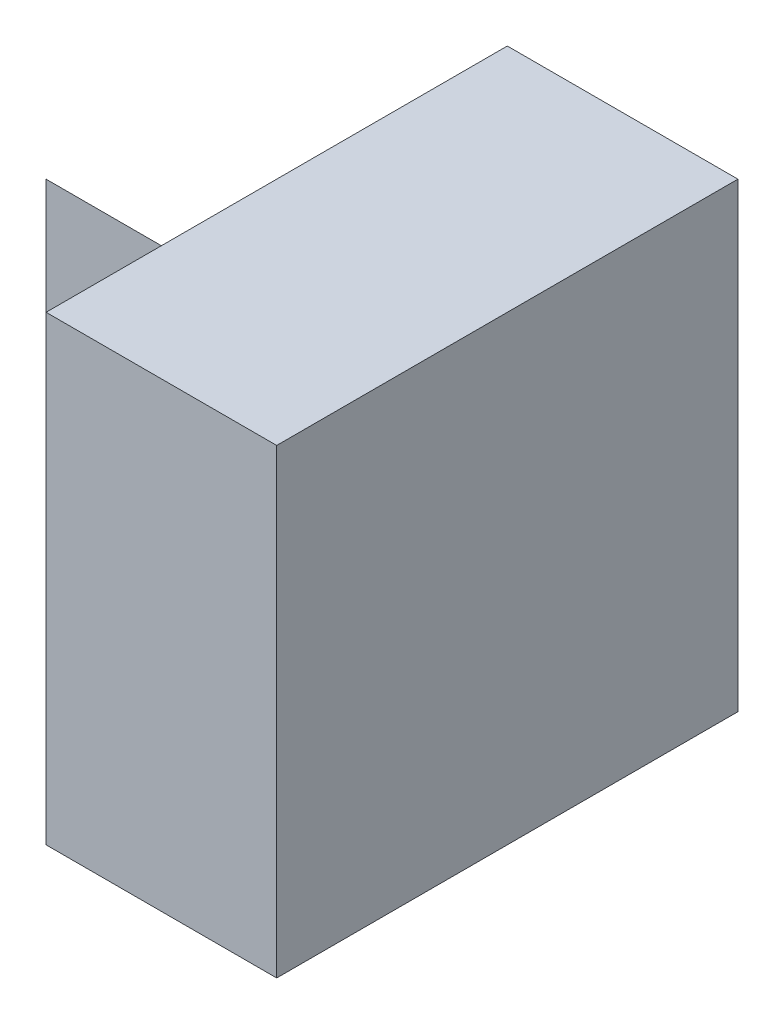
from build123d import *

# Parameters (mm, degrees)
SKETCH1_W           = 4
SKETCH1_H           = 4
BOSS_EXTRUDE1_DEPTH = 2
SKETCH2_W           = 2
SKETCH2_H           = 3
BOSS_EXTRUDE2_DEPTH = 2
CUT_EXTRUDE1_DEPTH  = 2


with BuildPart() as part:
    # Sketch1 → Boss-Extrude1 (new body)
    with BuildSketch(Plane(origin=(0, 0, 0), x_dir=(0, 0, -1), z_dir=(1, 0, 0))):
        with Locations((2, 2)):
            Rectangle(SKETCH1_W, SKETCH1_H)
    extrude(amount=BOSS_EXTRUDE1_DEPTH)

    # Sketch2 → Boss-Extrude2 (add)
    with BuildSketch(Plane.ZY):
        with Locations((-3, 1.5)):
            Rectangle(SKETCH2_W, SKETCH2_H)
    extrude(amount=BOSS_EXTRUDE2_DEPTH)

    # Sketch3 → Cut-Extrude1 (cut)
    with BuildSketch(Plane.ZY.offset(2)):
        Polygon((-2, 3), (-4, 0), (-4, 3), align=None)
    extrude(amount=-CUT_EXTRUDE1_DEPTH, mode=Mode.SUBTRACT)


solid = part.part
